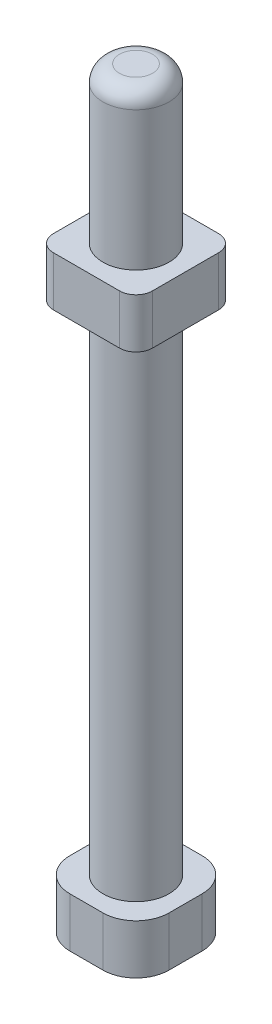
from build123d import *

# Parameters (mm, degrees)
SKETCH2_W           = 6
SKETCH2_H           = 6
BOSS_EXTRUDE1_DEPTH = 3
FILLET7_R           = 2
SKETCH3_R           = 2
BOSS_EXTRUDE2_DEPTH = 42.5
FILLET9_R           = 1
BOSS_EXTRUDE3_START = -9.4
SKETCH4_W           = 6
SKETCH4_H           = 6
BOSS_EXTRUDE3_DEPTH = 3
FILLET10_R          = 1


with BuildPart() as part:
    # Sketch2 → Boss-Extrude1 (new body)
    with BuildSketch(Plane(origin=(0, 0, 0), x_dir=(1, 0, 0), z_dir=(0, 1, 0))):
        Rectangle(SKETCH2_W, SKETCH2_H)
    extrude(amount=BOSS_EXTRUDE1_DEPTH)

    # Fillet7
    fillet7_edges = [part.edges().sort_by_distance(p)[0] for p in [
        (3, 1.5, 3),
        (-3, 1.5, 3),
        (-3, 1.5, -3),
        (3, 1.5, -3),
    ]]
    fillet(fillet7_edges, radius=FILLET7_R)

    # Sketch3 → Boss-Extrude2 (add)
    with BuildSketch(Plane(origin=(0, 3, 0), x_dir=(1, 0, 0), z_dir=(0, 1, 0))):
        Circle(SKETCH3_R)
    extrude(amount=BOSS_EXTRUDE2_DEPTH)

    # Fillet9
    fillet9_edges = [part.edges().sort_by_distance(p)[0] for p in [
        (-2, 45.5, 0),
    ]]
    fillet(fillet9_edges, radius=FILLET9_R)

    # Sketch4 → Boss-Extrude3 (add)
    with BuildSketch(Plane(origin=(0, 45.5, 0), x_dir=(1, 0, 0), z_dir=(0, 1, 0)).offset(BOSS_EXTRUDE3_START)):
        Rectangle(SKETCH4_W, SKETCH4_H)
    extrude(amount=-BOSS_EXTRUDE3_DEPTH)

    # Fillet10
    fillet10_edges = [part.edges().sort_by_distance(p)[0] for p in [
        (-3, 34.6, 3),
        (-3, 34.6, -3),
        (3, 34.6, -3),
        (3, 34.6, 3),
    ]]
    fillet(fillet10_edges, radius=FILLET10_R)


solid = part.part
